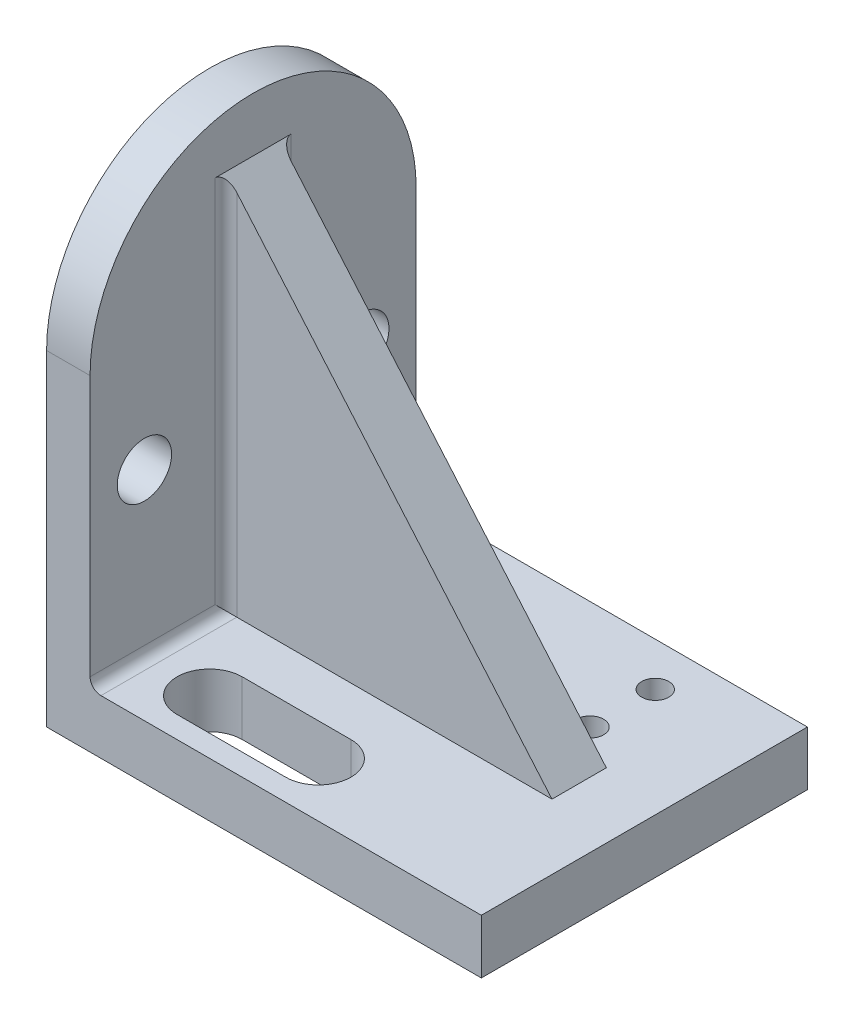
from build123d import *

# Parameters (mm, degrees)
SKETCH1_W           = 101.6
SKETCH1_H           = 76.2
BOSS_EXTRUDE4_DEPTH = 12.7
BOSS_EXTRUDE5_DEPTH = 10.16
SKETCH5_R           = 3.175
CUT_EXTRUDE1_DEPTH  = 120.811560377
SKETCH6_R           = 6.35
CUT_EXTRUDE2_DEPTH  = 152.252681299
RIB1_REACH          = 132.755
SKETCH7_WALL_W      = 380.597220188
SKETCH7_WALL_H      = 12.7
FILLET2_R           = 2.54


with BuildPart() as part:
    # Sketch1 → Boss-Extrude4 (new body)
    with BuildSketch(Plane(origin=(0, 0, 0), x_dir=(1, 0, 0), z_dir=(0, 1, 0))):
        Rectangle(SKETCH1_W, SKETCH1_H)
    extrude(amount=BOSS_EXTRUDE4_DEPTH)

    # Sketch4 → Boss-Extrude5 (add)
    with BuildSketch(Plane.ZY.offset(50.8)):
        with BuildLine():
            Line((38.1, 0), (38.1, 76.2))
            ThreePointArc((38.1, 76.2), (0, 114.3), (-38.1, 76.2))
            Line((-38.1, 76.2), (-38.1, 0))
            Line((-38.1, 0), (38.1, 0))
        make_face()
    extrude(amount=-BOSS_EXTRUDE5_DEPTH)

    # Sketch5 → Cut-Extrude1 (cut, through all)
    with BuildSketch(Plane(origin=(0, 12.7, 0), x_dir=(1, 0, 0), z_dir=(0, 1, 0))):
        with Locations(Location((-25.4, 27.94, 0), (0, 0, 270))):
            Circle(SKETCH5_R)
        with Locations(Location((25.4, 27.94, 0), (0, 0, 270))):
            Circle(SKETCH5_R)
        with Locations(Location((25.4, 12.7, 0), (0, 0, 270))):
            Circle(SKETCH5_R)
        with Locations(Location((-25.4, 12.7, 0), (0, 0, 270))):
            Circle(SKETCH5_R)
        with BuildLine():
            Line((-25.4, -17.78), (0, -17.78))
            ThreePointArc((0, -17.78), (7.62, -25.4), (0, -33.02))
            Line((0, -33.02), (-25.4, -33.02))
            ThreePointArc((-25.4, -33.02), (-33.02, -25.4), (-25.4, -17.78))
        make_face()
    extrude(amount=-CUT_EXTRUDE1_DEPTH, mode=Mode.SUBTRACT)

    # Sketch6 → Cut-Extrude2 (cut, through all)
    with BuildSketch(Plane(origin=(-40.64, 0, 0), x_dir=(0, 0, -1), z_dir=(1, 0, 0))):
        with Locations((-25.4, 50.8)):
            Circle(SKETCH6_R)
        with Locations(Location((25.4, 50.8, 0), (0, 0, 180))):
            Circle(SKETCH6_R)
    extrude(amount=-CUT_EXTRUDE2_DEPTH, mode=Mode.SUBTRACT)

    # Sketch7 wall → Rib1 (add, up to next)
    with BuildSketch(Plane(origin=(-2.54, 57.15, 0), x_dir=(0.650791373456, -0.759256602365, 0), z_dir=(0.759256602365, 0.650791373456, 0)), mode=Mode.PRIVATE) as rib1_sk1:
        Rectangle(SKETCH7_WALL_W, SKETCH7_WALL_H)
    rib1_tool1 = extrude(rib1_sk1.sketch, amount=-RIB1_REACH, mode=Mode.PRIVATE) - part.part
    add(rib1_tool1.solids().sort_by_distance((-2.54, 57.15, 0))[0])

    # Fillet2
    fillet2_edges = [part.edges().sort_by_distance(p)[0] for p in [
        (-40.64, 12.7, 22.225),
        (-40.64, 12.7, -22.225),
        (-40.64, 57.15, -6.35),
        (-40.64, 57.15, 6.35),
    ]]
    fillet(fillet2_edges, radius=FILLET2_R)


solid = part.part
